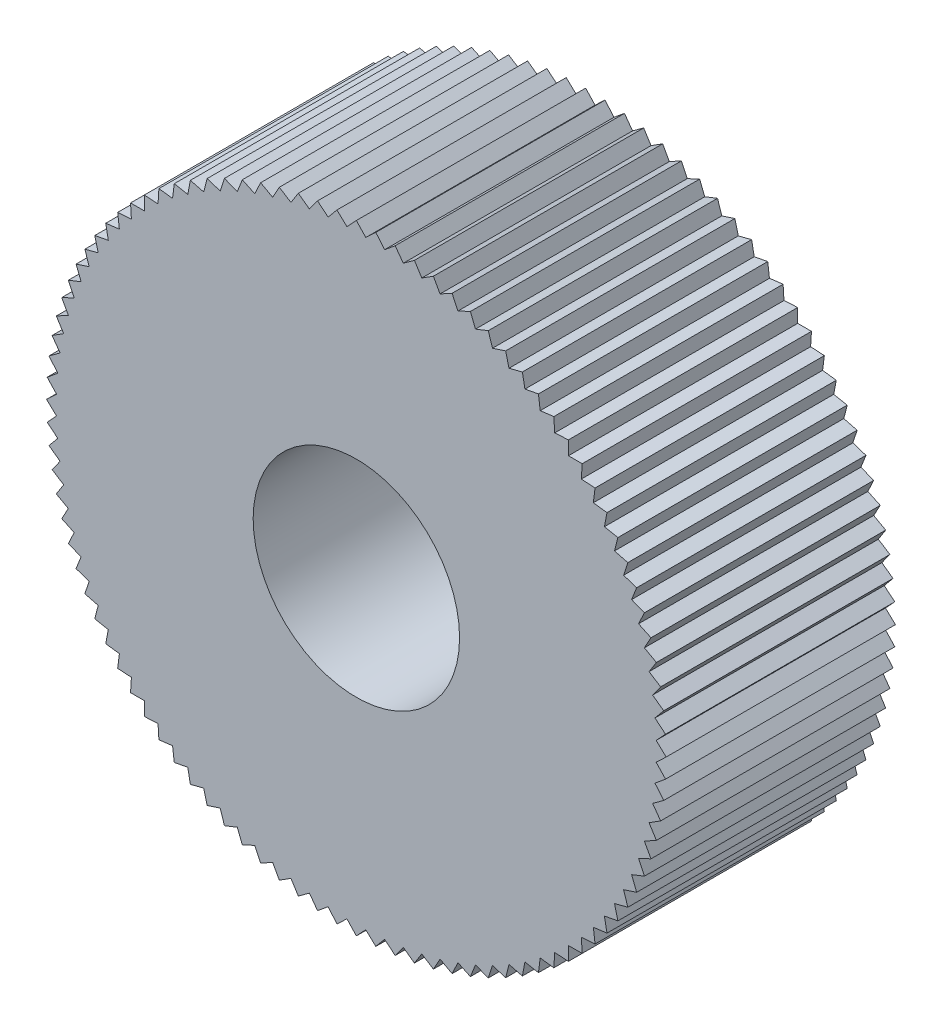
from build123d import *

# Parameters (mm, degrees)
SKETCH51_R          = 120.377360495
SKETCH51_R_2        = 45.016464451
BOSS_EXTRUDE1_DEPTH = 100
BOSS_EXTRUDE2_START = -100
BOSS_EXTRUDE2_DEPTH = 100
CIRPATTERN8_COUNT   = 100


with BuildPart() as part:
    # Sketch51 → Boss-Extrude1 (new body)
    with BuildSketch(Plane.XY):
        with Locations((0, 259.676946677)):
            Circle(SKETCH51_R)
        with Locations((0, 259.676946677)):
            Circle(SKETCH51_R_2, mode=Mode.SUBTRACT)
    extrude(amount=-BOSS_EXTRUDE1_DEPTH)

    # Sketch52 → Boss-Extrude2 (add)
    with BuildSketch(Plane.XY.offset(BOSS_EXTRUDE2_START)):
        Polygon((0, 394.791721389), (-7.354888585, 386.97195069), (-7.354888585, 362.220145345), (7.354888585, 362.220145345), (7.354888585, 386.97195069), align=None)
    boss_extrude2 = extrude(amount=BOSS_EXTRUDE2_DEPTH)

    # CirPattern8: Boss-Extrude2 ×100 about axis
    cirpattern8_axis = Axis((0, 259.676946677, 0), (0, 0, 1))
    for i in range(1, CIRPATTERN8_COUNT):
        add(boss_extrude2.rotate(cirpattern8_axis, i * 360 / CIRPATTERN8_COUNT))


solid = part.part
